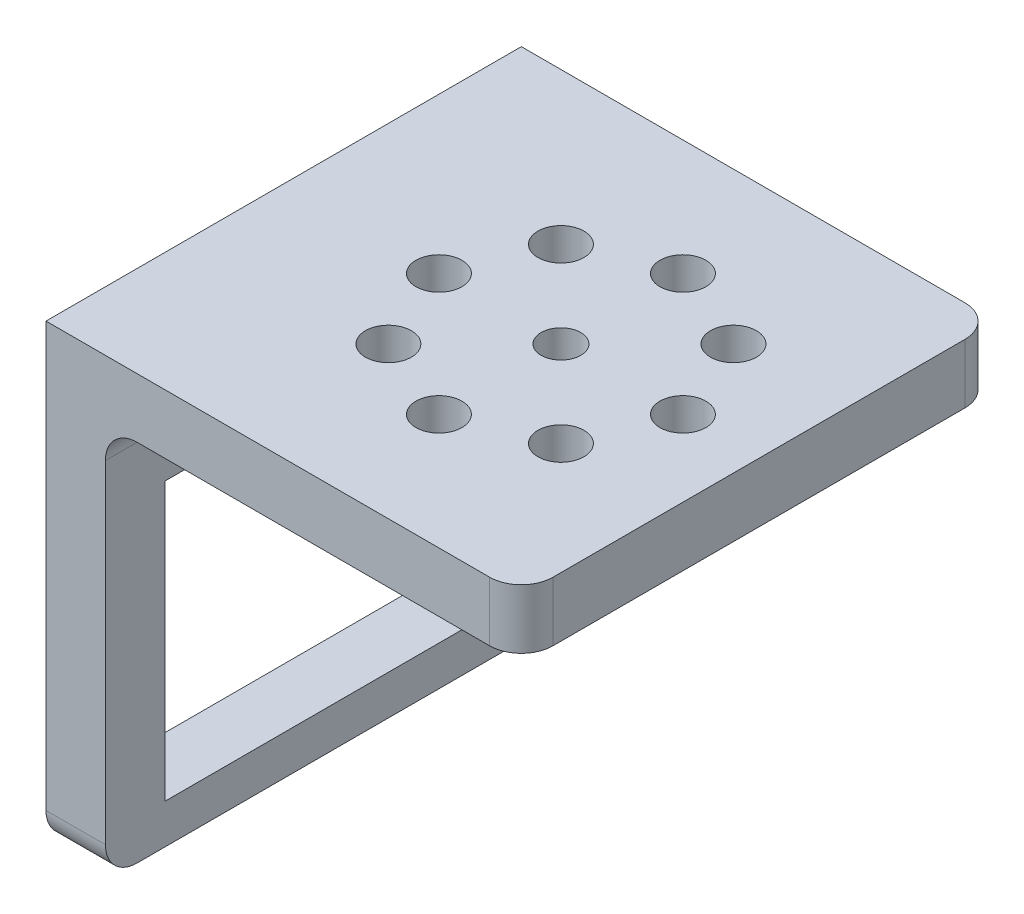
from build123d import *

# Parameters (mm, degrees)
BOSS_EXTRUDE1_DEPTH = 38.1
SKETCH2_W           = 28.575
SKETCH2_H           = 22.225
CUT_EXTRUDE1_DEPTH  = 39.1
SKETCH3_R           = 1.5875
CUT_EXTRUDE2_DEPTH  = 37.5125
SKETCH4_R           = 1.8415
CUT_EXTRUDE3_DEPTH  = 37.5125
CIRPATTERN1_COUNT   = 8
FILLET1_R           = 2.54
FILLET2_R           = 2.54


with BuildPart() as part:
    # Sketch1 → Boss-Extrude1 (new body)
    with BuildSketch(Plane.XY):
        Polygon((0, 0), (0, 31.75), (33.3375, 31.75), (33.3375, 36.5125), (-4.7625, 36.5125), (-4.7625, 0), align=None)
    extrude(amount=BOSS_EXTRUDE1_DEPTH)

    # Sketch2 → Cut-Extrude1 (cut, through all)
    with BuildSketch(Plane.ZY.offset(4.7625)):
        with Locations((19.05, 14.2875)):
            Rectangle(SKETCH2_W, SKETCH2_H)
    extrude(amount=-CUT_EXTRUDE1_DEPTH, mode=Mode.SUBTRACT)

    # Sketch3 → Cut-Extrude2 (cut, through all)
    with BuildSketch(Plane(origin=(0, 36.5125, 0), x_dir=(1, 0, 0), z_dir=(0, 1, 0))):
        with Locations((17.4625, -19.05)):
            Circle(SKETCH3_R)
    extrude(amount=-CUT_EXTRUDE2_DEPTH, mode=Mode.SUBTRACT)

    # Sketch4 → Cut-Extrude3 (cut, through all)
    with BuildSketch(Plane(origin=(0, 36.5125, 0), x_dir=(1, 0, 0), z_dir=(0, 1, 0))):
        with Locations((27.2415, -19.05)):
            Circle(SKETCH4_R)
    cut_extrude3 = extrude(amount=-CUT_EXTRUDE3_DEPTH, mode=Mode.SUBTRACT)

    # CirPattern1: Cut-Extrude3 ×8 about axis
    cirpattern1_axis = Axis((17.4625, 0, 19.05), (0, 1, 0))
    for i in range(1, CIRPATTERN1_COUNT):
        add(cut_extrude3.rotate(cirpattern1_axis, i * 360 / CIRPATTERN1_COUNT), mode=Mode.SUBTRACT)

    # Fillet1
    fillet1_edges = [part.edges().sort_by_distance(p)[0] for p in [
        (0, 31.75, 19.05),
    ]]
    fillet(fillet1_edges, radius=FILLET1_R)

    # Fillet2
    fillet2_edges = [part.edges().sort_by_distance(p)[0] for p in [
        (33.3375, 34.13125, 38.1),
        (-2.38125, 0, 38.1),
        (33.3375, 34.13125, 0),
        (-2.38125, 0, 0),
    ]]
    fillet(fillet2_edges, radius=FILLET2_R)


solid = part.part
